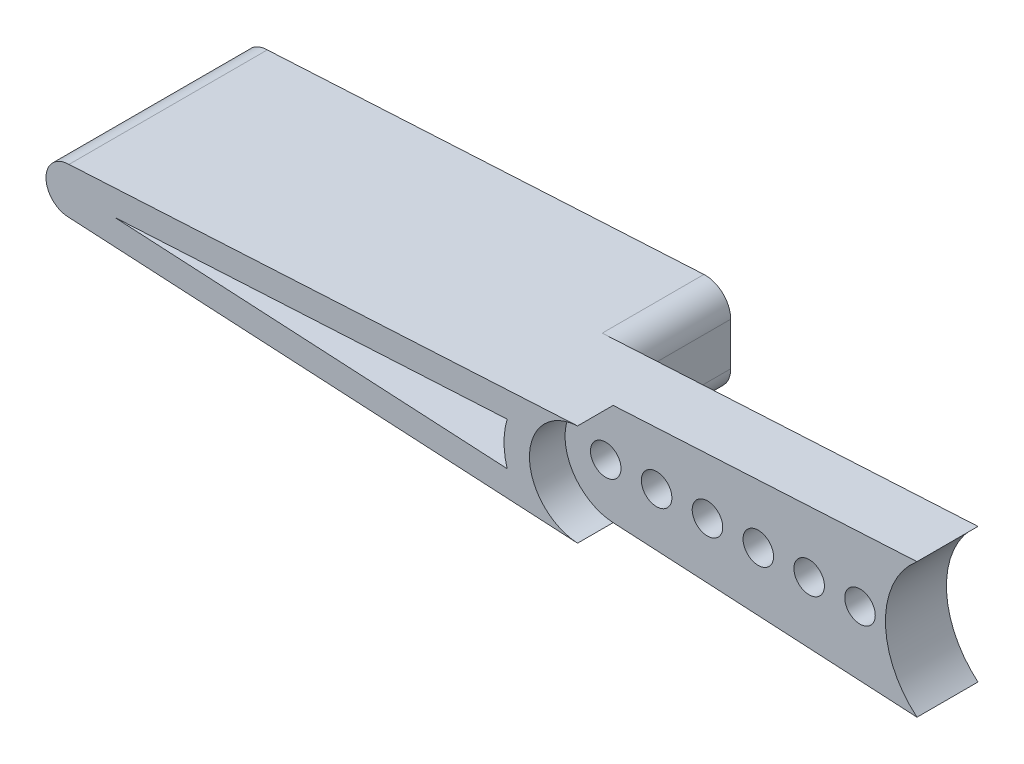
from build123d import *

# Parameters (mm, degrees)
SKETCH1_R           = 0.6
BOSS_EXTRUDE1_DEPTH = 2.4
BOSS_EXTRUDE2_DEPTH = 3.8
BOSS_EXTRUDE3_START = 4
BOSS_EXTRUDE3_DEPTH = 4


with BuildPart() as part:
    # Sketch1 → Boss-Extrude1 (new body)
    with BuildSketch(Plane.XY):
        with BuildLine():
            ThreePointArc((1.240927797, -2.65), (0, 0), (1.240927797, 2.65))
            Line((1.240927797, 2.65), (-10.709121967, 1.99702088))
            ThreePointArc((-10.709121967, 1.99702088), (-12.6, 0), (-10.709121967, -1.99702088))
            Line((-10.709121967, -1.99702088), (1.240927797, -2.65))
        make_face()
        with Locations((-11, 0)):
            Circle(SKETCH1_R, mode=Mode.SUBTRACT)
        with Locations((-9, 0)):
            Circle(SKETCH1_R, mode=Mode.SUBTRACT)
        with Locations((-7, 0)):
            Circle(SKETCH1_R, mode=Mode.SUBTRACT)
        with Locations((-5, 0)):
            Circle(SKETCH1_R, mode=Mode.SUBTRACT)
        with Locations((-3, 0)):
            Circle(SKETCH1_R, mode=Mode.SUBTRACT)
        with Locations((-1, 0)):
            Circle(SKETCH1_R, mode=Mode.SUBTRACT)
    extrude(amount=BOSS_EXTRUDE1_DEPTH)

    # Sketch1_4 → Boss-Extrude2 (add)
    with BuildSketch(Plane.XY):
        with BuildLine():
            ThreePointArc((-10.709121967, -1.99702088), (-12.6, 0), (-10.709121967, 1.99702088))
            Line((-10.709121967, 1.99702088), (-30.711406288, 0.904048527))
            ThreePointArc((-30.711406288, 0.904048527), (-31.615454815, 0), (-30.711406288, -0.904048527))
            Line((-30.711406288, -0.904048527), (-10.709121967, -1.99702088))
        make_face()
        with BuildLine():
            Line((-28.928115358, 0), (-13.478774997, 0.844188674))
            ThreePointArc((-13.478774997, 0.844188674), (-13.6, 0), (-13.478774997, -0.844188674))
            Line((-13.478774997, -0.844188674), (-28.928115358, 0))
        make_face(mode=Mode.SUBTRACT)
    extrude(amount=BOSS_EXTRUDE2_DEPTH)

    # Sketch2 → Boss-Extrude3 (add)
    with BuildSketch(Plane(origin=(0, 0, 0), x_dir=(-1, 0, 0), z_dir=(0, 0, -1)).offset(BOSS_EXTRUDE3_START)):
        with BuildLine():
            Line((12.484683103, 0.843865841), (12.484683103, -0.843865841))
            ThreePointArc((12.484683103, -0.843865841), (12.797137099, -1.570006662), (13.539244087, -1.842376282))
            Line((13.539244087, -1.842376282), (30.711406288, -0.904048527))
            ThreePointArc((30.711406288, -0.904048527), (31.615454815, 0), (30.711406288, 0.904048527))
            Line((30.711406288, 0.904048527), (13.539244087, 1.842376282))
            ThreePointArc((13.539244087, 1.842376282), (12.797137099, 1.570006662), (12.484683103, 0.843865841))
        make_face()
        with BuildLine():
            Line((28.928115358, 0), (13.478774997, -0.844188674))
            ThreePointArc((13.478774997, -0.844188674), (13.6, 0), (13.478774997, 0.844188674))
            Line((13.478774997, 0.844188674), (28.928115358, 0))
        make_face(mode=Mode.SUBTRACT)
    extrude(amount=-BOSS_EXTRUDE3_DEPTH)


solid = part.part
